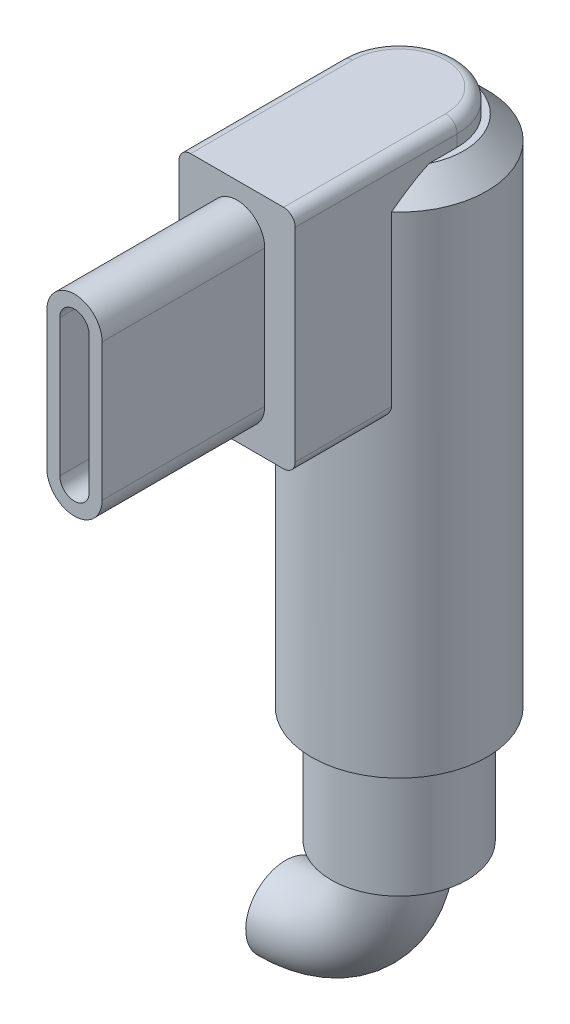
from build123d import *

# Parameters (mm, degrees)
SKETCH1_R           = 2.925
BOSS_EXTRUDE1_DEPTH = 5
SKETCH2_R           = 3.775
BOSS_EXTRUDE2_DEPTH = 23.1
BOSS_EXTRUDE3_START = -0.946462
SKETCH3_W           = 5
SKETCH3_H           = 9.75
BOSS_EXTRUDE3_DEPTH = 4.146462
BOSS_EXTRUDE4_DEPTH = 7
CUT_EXTRUDE1_DEPTH  = 1
CHAMFER1_SIZE       = 1
FILLET1_R           = 0.5
SKETCH6_R           = 1.7145
REVOLVE1_ANGLE      = 90


with BuildPart() as part:
    # Sketch1 → Boss-Extrude1 (new body)
    with BuildSketch(Plane(origin=(0, 0, 0), x_dir=(1, 0, 0), z_dir=(0, 1, 0))):
        Circle(SKETCH1_R)
    extrude(amount=BOSS_EXTRUDE1_DEPTH)

    # Sketch2 → Boss-Extrude2 (add)
    with BuildSketch(Plane(origin=(0, 5, 0), x_dir=(1, 0, 0), z_dir=(0, 1, 0))):
        Circle(SKETCH2_R)
    extrude(amount=BOSS_EXTRUDE2_DEPTH)

    # Sketch3 → Boss-Extrude3 (add)
    with BuildSketch(Plane.XY.offset(3.775).offset(BOSS_EXTRUDE3_START)):
        with Locations((0, 23.225)):
            Rectangle(SKETCH3_W, SKETCH3_H)
    extrude(amount=BOSS_EXTRUDE3_DEPTH)

    # Sketch4 → Boss-Extrude4 (add)
    with BuildSketch(Plane.XY.offset(6.975)):
        with BuildLine():
            Line((1.19, 26.175), (1.19, 20.275))
            ThreePointArc((1.19, 20.275), (0, 19.085), (-1.19, 20.275))
            Line((-1.19, 20.275), (-1.19, 26.175))
            ThreePointArc((-1.19, 26.175), (0, 27.365), (1.19, 26.175))
        make_face()
        with BuildLine():
            Line((0.63, 26.175), (0.63, 20.275))
            ThreePointArc((0.63, 20.275), (0, 19.645), (-0.63, 20.275))
            Line((-0.63, 20.275), (-0.63, 26.175))
            ThreePointArc((-0.63, 26.175), (0, 26.805), (0.63, 26.175))
        make_face(mode=Mode.SUBTRACT)
    extrude(amount=BOSS_EXTRUDE4_DEPTH)

    # Sketch5 → Cut-Extrude1 (cut)
    with BuildSketch(Plane(origin=(0, 28.1, 0), x_dir=(1, 0, 0), z_dir=(0, 1, 0))):
        with BuildLine():
            Line((2.5, 0), (2.5, -2.828537608))
            ThreePointArc((2.5, -2.828537608), (0, 3.775), (-2.5, -2.828537608))
            Line((-2.5, -2.828537608), (-2.5, 0))
            ThreePointArc((-2.5, 0), (0, 2.5), (2.5, 0))
        make_face()
    extrude(amount=-CUT_EXTRUDE1_DEPTH, mode=Mode.SUBTRACT)

    # Chamfer1
    chamfer1_edges = [part.edges().sort_by_distance(p)[0] for p in [
        (-1.55130993, 27.1, -3.441520376),
    ]]
    chamfer(chamfer1_edges, length=CHAMFER1_SIZE)

    # Fillet1
    fillet1_edges = [part.edges().sort_by_distance(p)[0] for p in [
        (-2.5, 28.1, 3.4875),
        (-2.5, 18.35, 4.901769),
        (2.5, 18.35, 4.901769),
        (2.5, 28.1, 3.4875),
        (0, 28.1, -2.5),
    ]]
    fillet(fillet1_edges, radius=FILLET1_R)

    # Sketch6 → Revolve1 (revolve)
    with BuildSketch(Plane.XZ):
        Circle(SKETCH6_R)
    revolve(axis=Axis((-4.8895, 0, -6.893491053), (0, 0, -1)), revolution_arc=REVOLVE1_ANGLE)


solid = part.part
